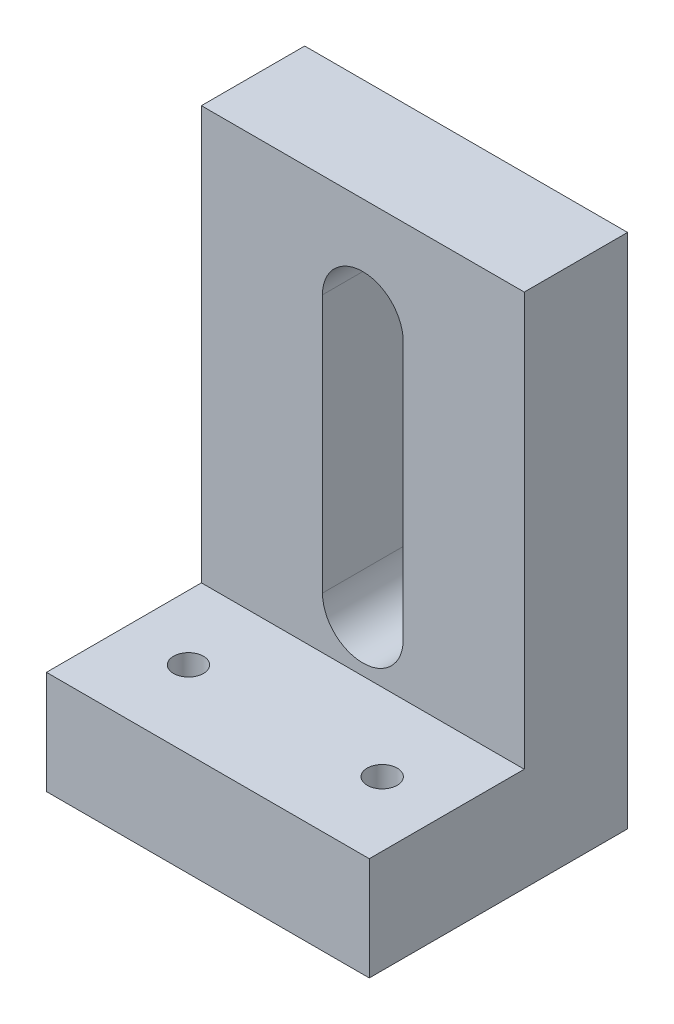
from build123d import *

# Parameters (mm, degrees)
BOSS_EXTRUDE1_DEPTH = 31.75
CUT_EXTRUDE1_DEPTH  = 11.16
SKETCH5_R           = 1.4732
CUT_EXTRUDE2_DEPTH  = 11.16


with BuildPart() as part:
    # Sketch3 → Boss-Extrude1 (new body)
    with BuildSketch(Plane(origin=(0, 0, 0), x_dir=(0, 0, -1), z_dir=(1, 0, 0))):
        Polygon((0, 0), (25.4, 0), (25.4, 50.8), (15.24, 50.8), (15.24, 10.16), (0, 10.16), align=None)
    extrude(amount=-BOSS_EXTRUDE1_DEPTH)

    # Sketch4 → Cut-Extrude1 (cut, through all)
    with BuildSketch(Plane.XY.offset(-15.24)):
        with BuildLine():
            Line((-19.84375, 40.64), (-19.84375, 15.24))
            ThreePointArc((-19.84375, 15.24), (-15.875, 11.27125), (-11.90625, 15.24))
            Line((-11.90625, 15.24), (-11.90625, 40.64))
            ThreePointArc((-11.90625, 40.64), (-15.875, 44.60875), (-19.84375, 40.64))
        make_face()
    extrude(amount=-CUT_EXTRUDE1_DEPTH, mode=Mode.SUBTRACT)

    # Sketch5 → Cut-Extrude2 (cut, through all)
    with BuildSketch(Plane(origin=(0, 10.16, 0), x_dir=(1, 0, 0), z_dir=(0, 1, 0))):
        with Locations((-25.4, 7.62)):
            Circle(SKETCH5_R)
        with Locations((-6.35, 7.62)):
            Circle(SKETCH5_R)
    extrude(amount=-CUT_EXTRUDE2_DEPTH, mode=Mode.SUBTRACT)


solid = part.part
